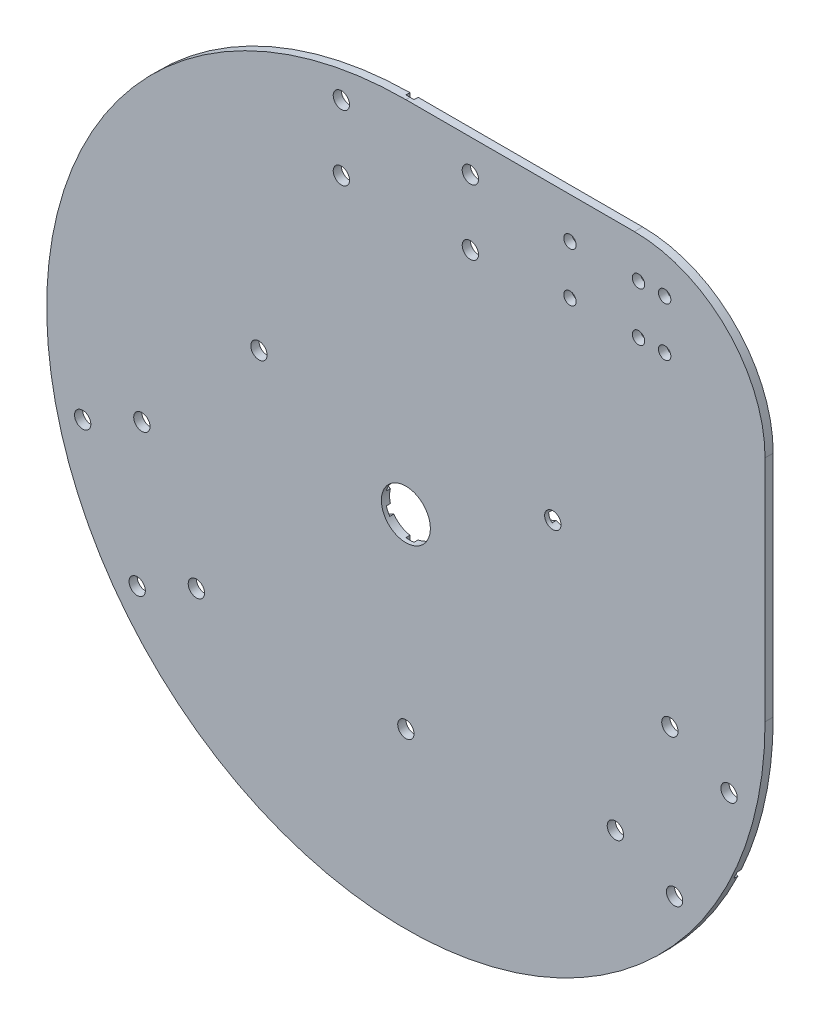
from build123d import *

# Parameters (mm, degrees)
BOSS_EXTRUDE1_DEPTH = 3.175
CUT_EXTRUDE3_DEPTH  = 1.5875
SKETCH3_R           = 9.525
CUT_EXTRUDE4_DEPTH  = 198.591145108
SKETCH2_4_R         = 3.175
CUT_EXTRUDE5_DEPTH  = 198.591145108
FILLET1_R           = 50.8
SKETCH8_R           = 3.175
CUT_EXTRUDE7_DEPTH  = 198.591145108
SKETCH9_R           = 2.413
CUT_EXTRUDE8_DEPTH  = 198.591145108


with BuildPart() as part:
    # Sketch1 → Boss-Extrude1 (new body)
    with BuildSketch(Plane.XY):
        with BuildLine():
            Line((0, 139.7), (139.7, 139.7))
            Line((139.7, 139.7), (139.7, 0))
            ThreePointArc((139.7, 0), (-98.782817332, -98.782817332), (0, 139.7))
        make_face()
    extrude(amount=BOSS_EXTRUDE1_DEPTH)

    # Sketch2 → Cut-Extrude3 (cut)
    with BuildSketch(Plane(origin=(0, 0, 0), x_dir=(-1, 0, 0), z_dir=(0, 0, -1))):
        with BuildLine():
            ThreePointArc((-127.273929282, -57.597195461), (-126.611197849, -59.039771165), (-125.932116301, -60.474722685))
            Line((-125.932116301, -60.474722685), (-1.5875, -2.491875854))
            Line((-1.5875, -2.491875854), (-1.5875, -69.587590332))
            ThreePointArc((-1.5875, -69.587590332), (0, -69.162220989), (1.5875, -69.587590332))
            Line((1.5875, -69.587590332), (1.5875, -2.491875854))
            Line((1.5875, -2.491875854), (125.932116301, -60.474722685))
            ThreePointArc((125.932116301, -60.474722685), (126.611197849, -59.039771165), (127.273929282, -57.597195461))
            Line((127.273929282, -57.597195461), (3.756345013, 0))
            Line((3.756345013, 0), (55.328894815, 24.048674923))
            ThreePointArc((55.328894815, 24.048674923), (54.272472776, 25.307669683), (53.987081834, 26.926202147))
            Line((53.987081834, 26.926202147), (1.5875, 2.491875854))
            Line((1.5875, 2.491875854), (1.5875, 139.690979822))
            ThreePointArc((1.5875, 139.690979822), (0.793762813, 139.697744937), (0, 139.7))
            Line((0, 139.7), (-1.5875, 139.7))
            Line((-1.5875, 139.7), (-1.5875, 2.491875854))
            Line((-1.5875, 2.491875854), (-53.987081834, 26.926202147))
            ThreePointArc((-53.987081834, 26.926202147), (-54.272472776, 25.307669683), (-55.328894815, 24.048674923))
            Line((-55.328894815, 24.048674923), (-3.756345013, 0))
            Line((-3.756345013, 0), (-127.273929282, -57.597195461))
        make_face()
    extrude(amount=-CUT_EXTRUDE3_DEPTH, mode=Mode.SUBTRACT)

    # Sketch3 → Cut-Extrude4 (cut, through all)
    with BuildSketch(Plane.XY.offset(3.175)):
        Circle(SKETCH3_R)
    extrude(amount=-CUT_EXTRUDE4_DEPTH, mode=Mode.SUBTRACT)

    # Sketch2_4 → Cut-Extrude5 (cut, through all)
    with BuildSketch(Plane(origin=(0, 0, 0), x_dir=(-1, 0, 0), z_dir=(0, 0, -1))):
        with Locations((0, -72.337220989)):
            Circle(SKETCH2_4_R)
        with Locations((-57.15, 26.649482664)):
            Circle(SKETCH2_4_R)
        with Locations((57.15, 26.649482664)):
            Circle(SKETCH2_4_R)
    extrude(amount=-CUT_EXTRUDE5_DEPTH, mode=Mode.SUBTRACT)

    # Fillet1
    fillet1_edges = [part.edges().sort_by_distance(p)[0] for p in [
        (139.7, 139.7, 1.5875),
    ]]
    fillet(fillet1_edges, radius=FILLET1_R)

    # Sketch8 → Cut-Extrude7 (cut, through all)
    with BuildSketch(Plane.XY.offset(3.175)):
        with Locations((25.0825, 101.6)):
            Circle(SKETCH8_R)
        with Locations((-25.0825, 101.6)):
            Circle(SKETCH8_R)
        with Locations((-25.0825, 127)):
            Circle(SKETCH8_R)
        with Locations((25.0825, 127)):
            Circle(SKETCH8_R)
        with Locations((102.681193713, -20.205550325)):
            Circle(SKETCH8_R)
        with Locations((125.701411504, -30.940054173)):
            Circle(SKETCH8_R)
        with Locations((81.480548613, -65.670480461)):
            Circle(SKETCH8_R)
        with Locations((104.500766404, -76.404984309)):
            Circle(SKETCH8_R)
        with Locations((-81.480548613, -65.670480461)):
            Circle(SKETCH8_R)
        with Locations((-104.500766404, -76.404984309)):
            Circle(SKETCH8_R)
        with Locations((-102.681193713, -20.205550325)):
            Circle(SKETCH8_R)
        with Locations((-125.701411504, -30.940054173)):
            Circle(SKETCH8_R)
    extrude(amount=-CUT_EXTRUDE7_DEPTH, mode=Mode.SUBTRACT)

    # Sketch9 → Cut-Extrude8 (cut, through all)
    with BuildSketch(Plane.XY.offset(3.175)):
        with Locations((90.4875, 104.775)):
            Circle(SKETCH9_R)
        with Locations((90.4875, 123.825)):
            Circle(SKETCH9_R)
        with Locations((100.6475, 104.775)):
            Circle(SKETCH9_R)
        with Locations((100.6475, 123.825)):
            Circle(SKETCH9_R)
        with Locations((63.8175, 104.775)):
            Circle(SKETCH9_R)
        with Locations((63.8175, 123.825)):
            Circle(SKETCH9_R)
    extrude(amount=-CUT_EXTRUDE8_DEPTH, mode=Mode.SUBTRACT)


solid = part.part
